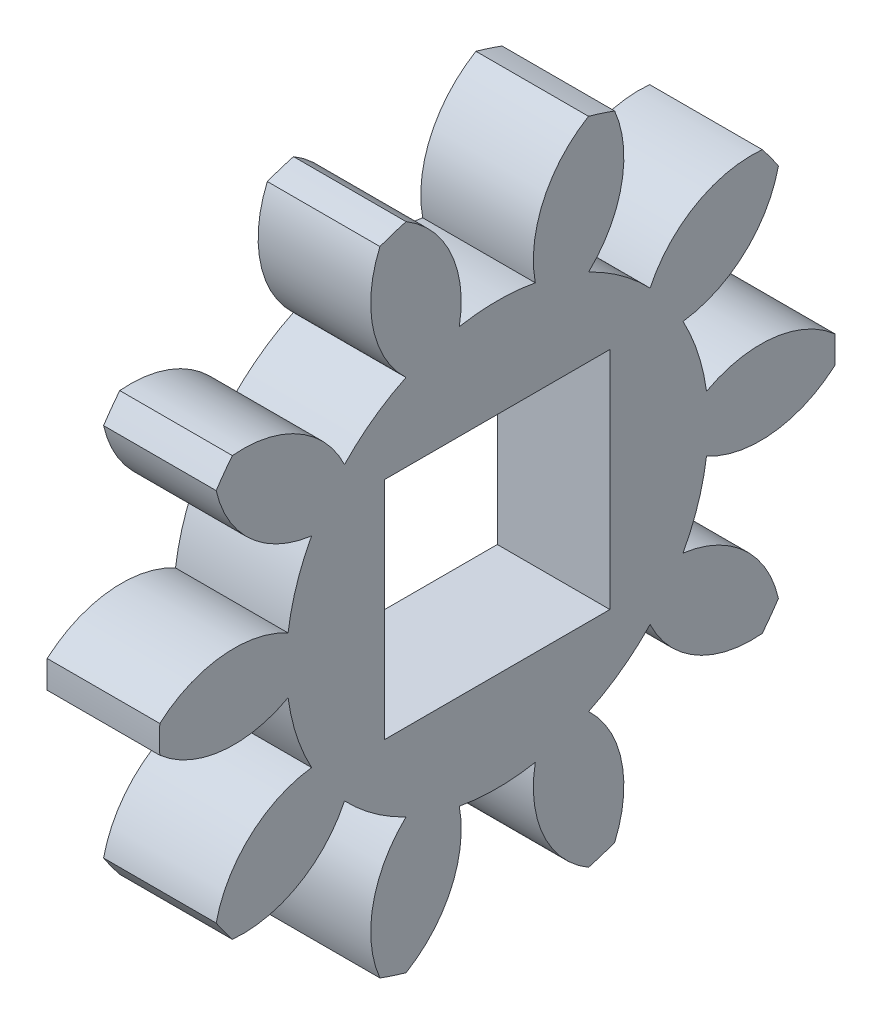
from build123d import *

# Parameters (mm, degrees)
BASPROSKE_W         = 4
BASPROSKE_H         = 12
TOOTHCUT_DEPTH      = 18.435595774
TEETHCUTS_COUNT     = 10
TEETHCUTS_ANGLE     = 324
BORSKE_R            = 1
BORE_DEPTH          = 50.0000508
SKETCH_1_W          = 8
SKETCH_1_H          = 8
CUT_EXTRUDE_2_DEPTH = 18.131831434


with BuildPart() as part:
    # BasProSke → Base-Revolve (revolve)
    with BuildSketch(Plane(origin=(0, 0, 0), x_dir=(1, 0, 0), z_dir=(0, 1, 0))):
        with Locations((2, 6)):
            Rectangle(BASPROSKE_W, BASPROSKE_H)
    revolve(axis=Axis((-10, 0, 0), (1, 0, 0)))

    # TooCutSke → ToothCut (cut, through all)
    with BuildSketch(Plane(origin=(0, 0, 0), x_dir=(0, 0, -1), z_dir=(1, 0, 0))):
        with BuildLine():
            ThreePointArc((1.349961767, 7.376489967), (0, 7.499), (-1.349961767, 7.376489967))
            ThreePointArc((-1.349961767, 7.376489967), (-1.644412889, 9.779161882), (-3.270793922, 11.572041837))
            ThreePointArc((-3.270793922, 11.572041837), (0, 12.0254), (3.270793922, 11.572041837))
            ThreePointArc((3.270793922, 11.572041837), (1.644412889, 9.779161882), (1.349961767, 7.376489967))
        make_face()
    toothcut = extrude(amount=TOOTHCUT_DEPTH, mode=Mode.SUBTRACT)

    # TeethCuts: ToothCut ×10 about axis
    teethcuts_axis = Axis((-10, 0, 0), (1, 0, 0))
    for i in range(1, TEETHCUTS_COUNT):
        add(toothcut.rotate(teethcuts_axis, i * TEETHCUTS_ANGLE / (TEETHCUTS_COUNT - 1)), mode=Mode.SUBTRACT)

    # BorSke → Bore (cut, symmetric)
    with BuildSketch(Plane(origin=(0, 0, 0), x_dir=(0, 0, -1), z_dir=(1, 0, 0))):
        Circle(BORSKE_R)
    extrude(amount=BORE_DEPTH, both=True, mode=Mode.SUBTRACT)

    # 草图1 → 切除-拉伸2 (cut, through all)
    with BuildSketch(Plane.ZY):
        Rectangle(SKETCH_1_W, SKETCH_1_H)
    extrude(amount=-CUT_EXTRUDE_2_DEPTH, mode=Mode.SUBTRACT)


solid = part.part
